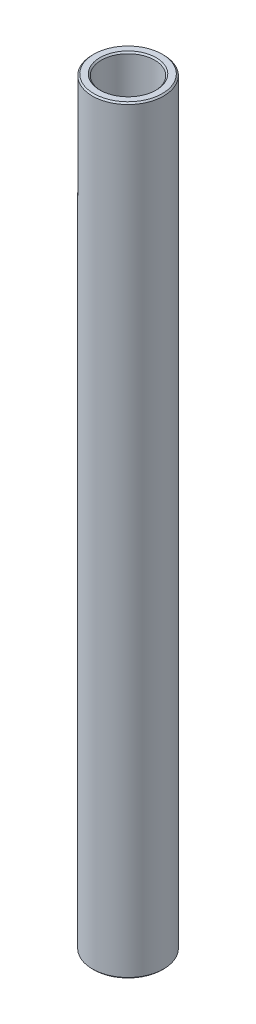
from build123d import *

# Parameters (mm, degrees)
SKETCH1_W     = 1.5875
SKETCH1_H     = 135.334375
CHAMFER1_SIZE = 0.254


with BuildPart() as part:
    # Sketch1 → Revolve1 (revolve)
    with BuildSketch(Plane.XY):
        with Locations((5.55625, 138.310882465)):
            Rectangle(SKETCH1_W, SKETCH1_H)
    revolve(axis=Axis((0, 61.118694965, 0), (0, 1, 0)))

    # Chamfer1
    chamfer1_edges = [part.edges().sort_by_distance(p)[0] for p in [
        (-6.35, 70.643694965, 0),
        (-6.349999999, 205.978069965, 0),
        (-4.762499999, 205.978069965, 0),
        (-4.7625, 70.643694965, 0),
    ]]
    chamfer(chamfer1_edges, length=CHAMFER1_SIZE)


solid = part.part
